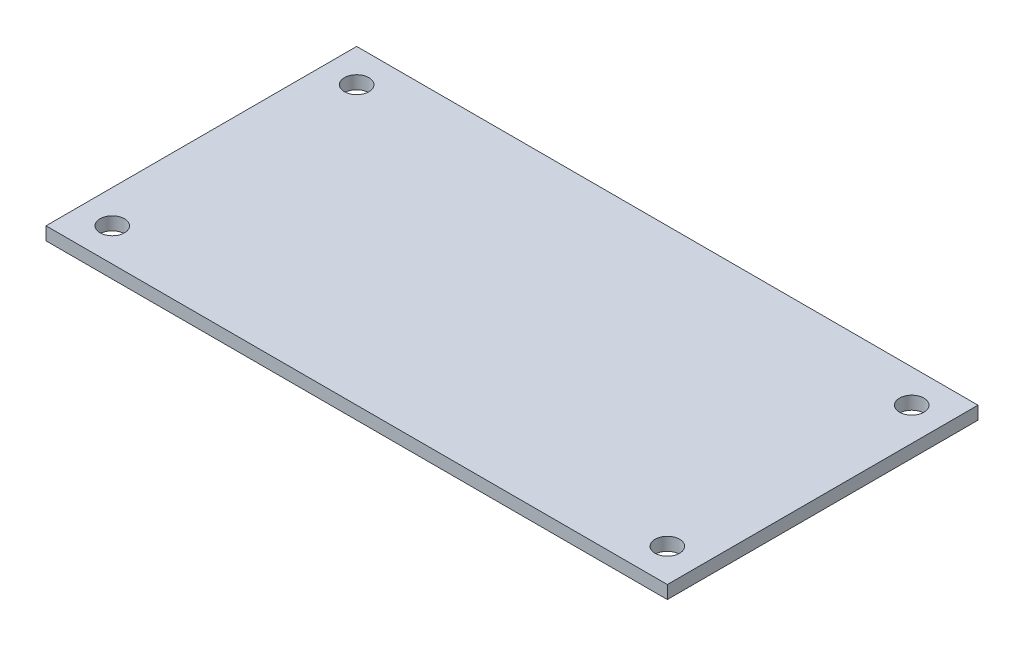
from build123d import *

# Parameters (mm, degrees)
SKETCH1_W           = 76.2
SKETCH1_H           = 38.1
SKETCH1_R           = 1.5
BOSS_EXTRUDE1_DEPTH = 1.6


with BuildPart() as part:
    # Sketch1 → Boss-Extrude1 (new body)
    with BuildSketch(Plane(origin=(0, 0, 0), x_dir=(1, 0, 0), z_dir=(0, 1, 0))):
        Rectangle(SKETCH1_W, SKETCH1_H)
        with Locations((-34.036, 14.986)):
            Circle(SKETCH1_R, mode=Mode.SUBTRACT)
        with Locations((-34.036, -14.986)):
            Circle(SKETCH1_R, mode=Mode.SUBTRACT)
        with Locations((34.036, 14.986)):
            Circle(SKETCH1_R, mode=Mode.SUBTRACT)
        with Locations((34.036, -14.986)):
            Circle(SKETCH1_R, mode=Mode.SUBTRACT)
    extrude(amount=BOSS_EXTRUDE1_DEPTH)


solid = part.part
